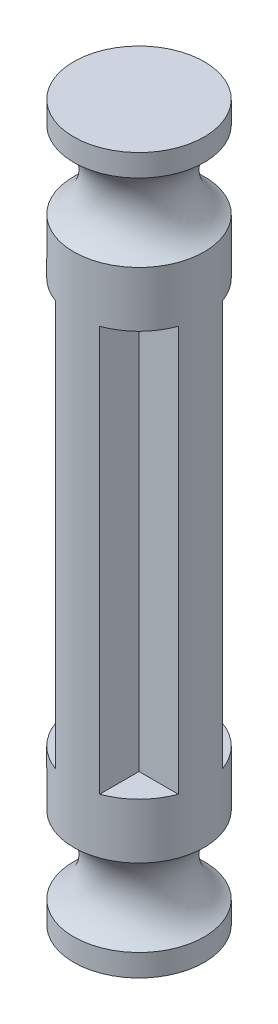
from build123d import *

# Parameters (mm, degrees)
EXTRUDE_2_DEPTH = 18.32


with BuildPart() as part:
    # 草图1 → 凸台-拉伸2 (new body)
    with BuildSketch(Plane(origin=(0, 0, 0), x_dir=(1, 0, 0), z_dir=(0, 1, 0))):
        with BuildLine():
            Line((1, 1), (1, 2.775338))
            ThreePointArc((1, 2.775338), (0, 2.95), (-1, 2.775338))
            Line((-1, 2.775338), (-1, 1))
            Line((-1, 1), (-2.775338, 1))
            ThreePointArc((-2.775338, 1), (-2.95, 0), (-2.775338, -1))
            Line((-2.775338, -1), (-1, -1))
            Line((-1, -1), (-1, -2.775338))
            ThreePointArc((-1, -2.775338), (0, -2.95), (1, -2.775338))
            Line((1, -2.775338), (1, -1))
            Line((1, -1), (2.775338, -1))
            ThreePointArc((2.775338, -1), (2.95, 0), (2.775338, 1))
            Line((2.775338, 1), (1, 1))
        make_face()
    extrude(amount=EXTRUDE_2_DEPTH)

    # 草图3 → 旋转3 (revolve)
    with BuildSketch(Plane(origin=(0, 0, 0), x_dir=(0, 0, -1), z_dir=(1, 0, 0))):
        with BuildLine():
            Line((0, 18.32), (0, 25.32))
            Line((0, 25.32), (2.95, 25.32))
            Line((2.95, 25.32), (2.95, 24.32))
            ThreePointArc((2.95, 24.32), (1.918246, 22.57), (2.95, 20.82))
            Line((2.95, 20.82), (2.95, 18.32))
            Line((2.95, 18.32), (0, 18.32))
        make_face()
        with BuildLine():
            Line((0, 0), (0, -7))
            Line((0, -7), (2.95, -7))
            Line((2.95, -7), (2.95, -6))
            ThreePointArc((2.95, -6), (1.918246, -4.25), (2.95, -2.5))
            Line((2.95, -2.5), (2.95, 0))
            Line((2.95, 0), (0, 0))
        make_face()
    revolve(axis=Axis((0, 0, 0), (0, -1, 0)))


solid = part.part
